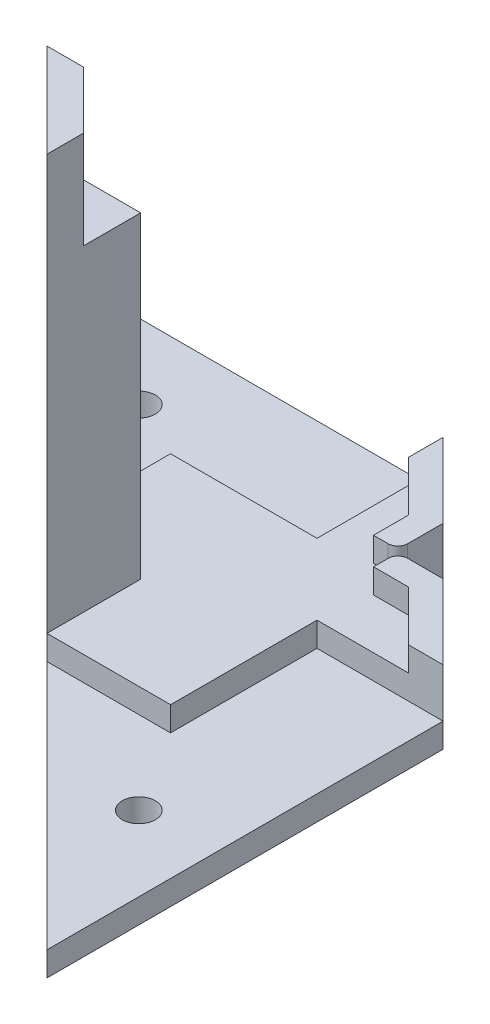
from build123d import *

# Parameters (mm, degrees)
BOSS_EXTRUDE1_DEPTH          = 3.175
BOSS_EXTRUDE2_DEPTH          = 3.175
FILLET1_R                    = 1.27
BOSS_EXTRUDE3_DEPTH          = 41.275
FILLET1_OF_MIRROR2_R         = 1.27
BOSS_EXTRUDE4_DEPTH          = 12.7
F_18_0_1695_DIAMETER_HOLE1_D = 4.3053
CUT_EXTRUDE1_DEPTH           = 9.525
BOSS_EXTRUDE5_DEPTH          = 3.175
F_18_0_1695_DIAMETER_HOLE2_D = 4.3053


with BuildPart() as part:
    # Sketch1 → Boss-Extrude1 (new body)
    with BuildSketch(Plane(origin=(0, 0, 0), x_dir=(1, 0, 0), z_dir=(0, 1, 0))):
        Polygon((34.984785044, 28.736819587), (28.736819587, 28.736819587), (0, 0), (28.272599075, 0), (28.272599075, 19.05), (44.671604631, 19.05), align=None)
    boss_extrude1 = extrude(amount=BOSS_EXTRUDE1_DEPTH)

    # Mirror1: Boss-Extrude1 across plane
    add(boss_extrude1.mirror(Plane(origin=(0, 3.175, 0), x_dir=(-0.7071067811865507, 0, 0.7071067811865444), z_dir=(-0.7071067811865446, 0, -0.7071067811865506))))

    # Sketch2 → Boss-Extrude2 (add)
    with BuildSketch(Plane(origin=(0, 3.175, 0), x_dir=(1, 0, 0), z_dir=(0, 1, 0))):
        Polygon((29.11502011, 25.561819587), (29.11502011, 28.736819587), (34.984785044, 28.736819587), (44.671604631, 19.05), (40.181476571, 19.05), (33.669656983, 25.561819587), align=None)
    boss_extrude2 = extrude(amount=BOSS_EXTRUDE2_DEPTH)

    # Fillet1
    fillet1_edges = [part.edges().sort_by_distance(p)[0] for p in [
        (29.11502011, 4.7625, -28.736819587),
    ]]
    fillet(fillet1_edges, radius=FILLET1_R)

    # Sketch2_3 → Boss-Extrude3 (add)
    with BuildSketch(Plane(origin=(0, 3.175, 0), x_dir=(1, 0, 0), z_dir=(0, 1, 0))):
        Polygon((12.192, 0), (12.192, 12.192), (6.096, 6.096), align=None)
    boss_extrude3 = extrude(amount=BOSS_EXTRUDE3_DEPTH)

    # Mirror2: Boss-Extrude2, Boss-Extrude3 across plane
    add(boss_extrude2.mirror(Plane(origin=(0, 0, 0), x_dir=(-0.7071067811865506, 0, 0.7071067811865445), z_dir=(0.7071067811865445, 0, 0.7071067811865506))))
    add(boss_extrude3.mirror(Plane(origin=(0, 0, 0), x_dir=(-0.7071067811865506, 0, 0.7071067811865445), z_dir=(0.7071067811865445, 0, 0.7071067811865506))))

    # Fillet1 of Mirror2
    fillet1_of_mirror2_edges = [part.edges().sort_by_distance(p)[0] for p in [
        (28.736819587, 4.7625, -29.11502011),
    ]]
    fillet(fillet1_of_mirror2_edges, radius=FILLET1_OF_MIRROR2_R)

    # Sketch4 → Boss-Extrude4 (add)
    with BuildSketch(Plane(origin=(0, 44.45, 0), x_dir=(1, 0, 0), z_dir=(0, 1, 0))):
        Polygon((12.192, 0), (0, 12.192), (4.7625, 12.192), (12.192, 4.7625), align=None)
    extrude(amount=BOSS_EXTRUDE4_DEPTH)

    # 18 _0.1695_ Diameter Hole1 (through all)
    with Locations(Plane(origin=(8.47725, 0, -8.47725), x_dir=(-0.7071067811865449, 0, -0.7071067811865502), z_dir=(0.7071067811865502, 0, -0.7071067811865449))):
        with Locations((0, 52.3875)):
            Hole(F_18_0_1695_DIAMETER_HOLE1_D / 2)

    # Sketch7 → Cut-Extrude1 (cut)
    with BuildSketch(Plane(origin=(0, 3.175, 0), x_dir=(1, 0, 0), z_dir=(0, 1, 0))):
        Polygon((0, 0), (12.192, 0), (0, 12.192), align=None)
    extrude(amount=-CUT_EXTRUDE1_DEPTH, mode=Mode.SUBTRACT)

    # Sketch8 → Boss-Extrude5 (add)
    with BuildSketch(Plane(origin=(0, 0, 0), x_dir=(-1, 0, 0), z_dir=(0, -1, 0))):
        Polygon((-6.096, 6.096), (32.479604631, 44.671604631), (-19.05, 44.671604631), (-28.736819587, 34.984785044), (-28.736819587, 28.736819587), align=None)
    boss_extrude5 = extrude(amount=BOSS_EXTRUDE5_DEPTH)

    # Mirror3: Boss-Extrude5 across plane
    add(boss_extrude5.mirror(Plane(origin=(0, 0, 0), x_dir=(-0.7071067811865506, 0, 0.7071067811865445), z_dir=(0.7071067811865445, 0, 0.7071067811865506))))

    # 18 _0.1695_ Diameter Hole2 (through all)
    with Locations(Plane(origin=(0, -3.175, 0), x_dir=(-1, 0, 0), z_dir=(0, -1, 0))):
        with Locations((-34.924989631, -10.778219281)):
            f_18_0_1695_diameter_hole2 = Hole(F_18_0_1695_DIAMETER_HOLE2_D / 2)

    # Mirror4: 18 _0.1695_ Diameter Hole2 across plane
    add(f_18_0_1695_diameter_hole2.mirror(Plane(origin=(0, 0, 0), x_dir=(-0.7071067811865506, 0, 0.7071067811865445), z_dir=(0.7071067811865445, 0, 0.7071067811865506))), mode=Mode.SUBTRACT)


solid = part.part
